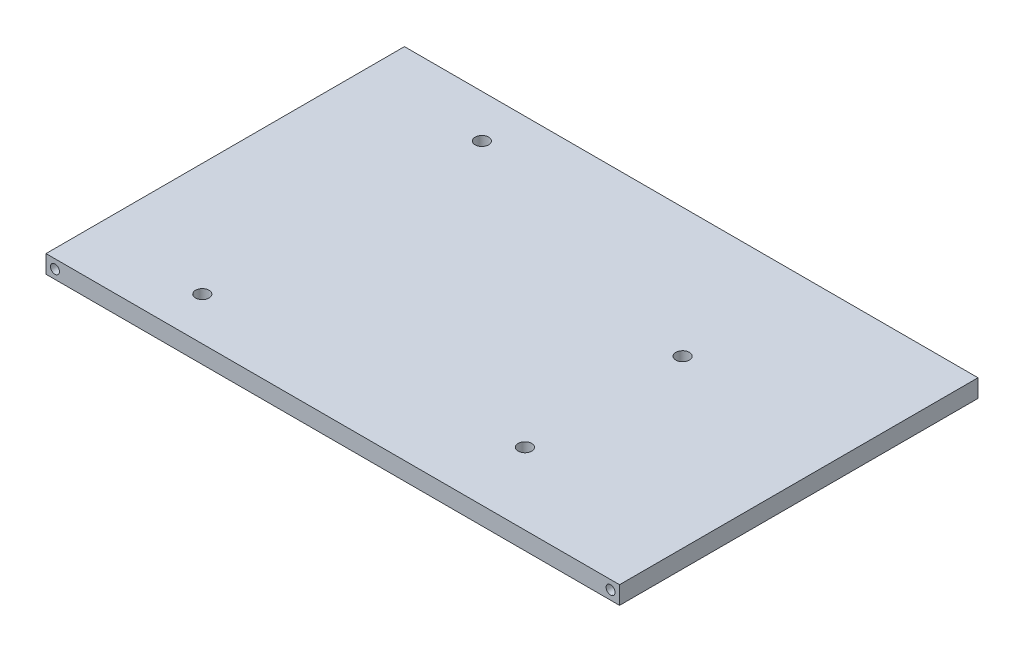
from build123d import *

# Parameters (mm, degrees)
SKETCH1_W           = 101.6
SKETCH1_H           = 63.5
BOSS_EXTRUDE1_DEPTH = 3.175
SKETCH2_R           = 0.79375
CUT_EXTRUDE1_DEPTH  = 6.35
SKETCH3_R           = 0.79375
CUT_EXTRUDE2_DEPTH  = 6.35
SKETCH4_R           = 1.19761
CUT_EXTRUDE3_DEPTH  = 4.175


with BuildPart() as part:
    # Sketch1 → Boss-Extrude1 (new body)
    with BuildSketch(Plane(origin=(0, 0, 0), x_dir=(1, 0, 0), z_dir=(0, 1, 0))):
        with Locations((8.595554542, -11.095875723)):
            Rectangle(SKETCH1_W, SKETCH1_H)
    extrude(amount=BOSS_EXTRUDE1_DEPTH)

    # Sketch2 → Cut-Extrude1 (cut)
    with BuildSketch(Plane.XY.offset(42.845875723)):
        with Locations((-40.616945458, 1.5875)):
            Circle(SKETCH2_R)
        with Locations((57.808054542, 1.5875)):
            Circle(SKETCH2_R)
    extrude(amount=-CUT_EXTRUDE1_DEPTH, mode=Mode.SUBTRACT)

    # Sketch3 → Cut-Extrude2 (cut)
    with BuildSketch(Plane(origin=(0, 0, -20.654124277), x_dir=(-1, 0, 0), z_dir=(0, 0, -1))):
        with Locations(Location((-57.808054542, 1.5875, 0), (0, 0, 180))):  # turned: the seam where the file's is
            Circle(SKETCH3_R)
        with Locations(Location((40.616945458, 1.5875, 0), (0, 0, 180))):  # turned: the seam where the file's is
            Circle(SKETCH3_R)
    extrude(amount=-CUT_EXTRUDE2_DEPTH, mode=Mode.SUBTRACT)

    # Sketch4 → Cut-Extrude3 (cut, through all)
    with BuildSketch(Plane(origin=(0, 3.175, 0), x_dir=(1, 0, 0), z_dir=(0, 1, 0))):
        with Locations(Location((-20.868445458, 13.034124277, 0), (0, 0, 270))):  # turned: the seam where the file's is
            Circle(SKETCH4_R)
        with Locations(Location((-22.138445458, -35.225875723, 0), (0, 0, 270))):  # turned: the seam where the file's is
            Circle(SKETCH4_R)
        with Locations(Location((29.931554542, -2.205875723, 0), (0, 0, 270))):  # turned: the seam where the file's is
            Circle(SKETCH4_R)
        with Locations(Location((29.931554542, -30.145875723, 0), (0, 0, 270))):  # turned: the seam where the file's is
            Circle(SKETCH4_R)
    extrude(amount=-CUT_EXTRUDE3_DEPTH, mode=Mode.SUBTRACT)


solid = part.part
